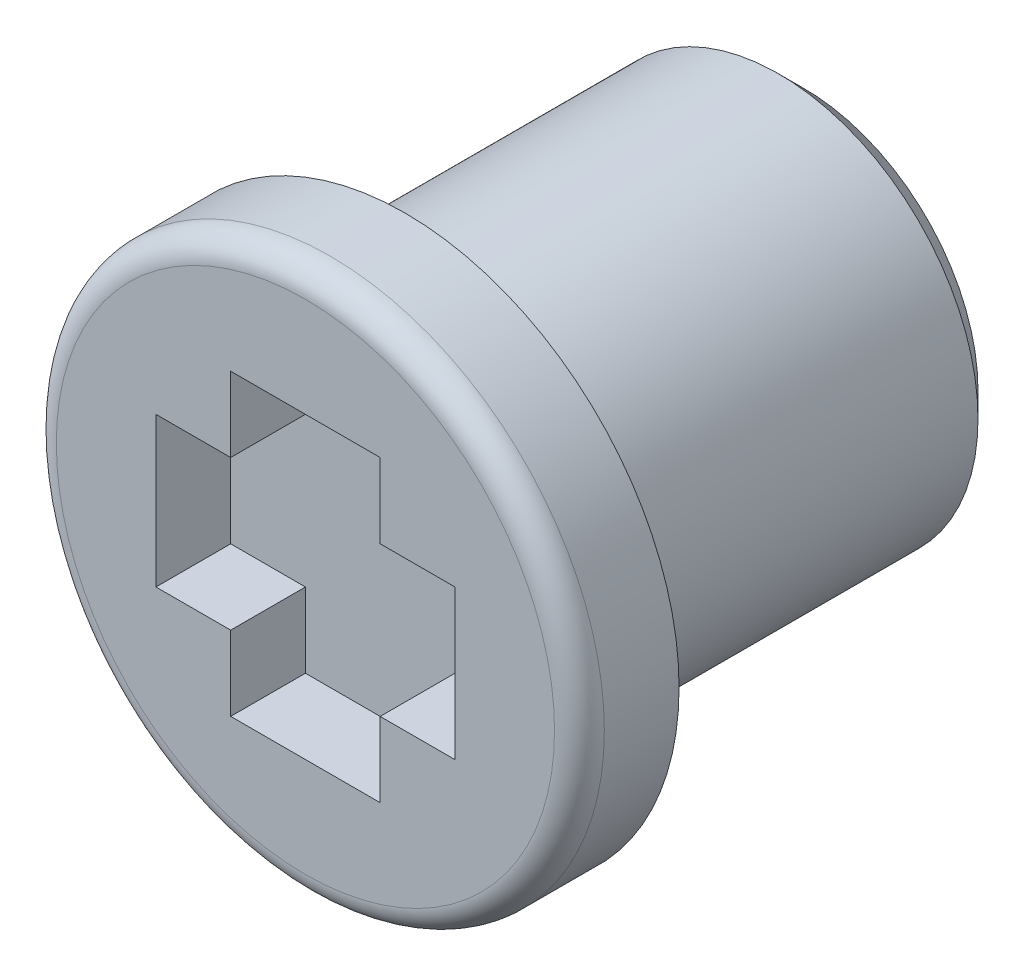
from build123d import *

# Parameters (mm, degrees)
SKETCH1_R           = 4
BOSS_EXTRUDE1_DEPTH = 8
SKETCH2_R           = 5.5
BOSS_EXTRUDE2_DEPTH = 2
CHAMFER1_SIZE       = 0.5
CUT_EXTRUDE1_DEPTH  = 1.5
FILLET1_R           = 0.5


with BuildPart() as part:
    # Sketch1 → Boss-Extrude1 (new body)
    with BuildSketch(Plane.XY):
        with Locations((0, 0.169439546)):
            Circle(SKETCH1_R)
    extrude(amount=BOSS_EXTRUDE1_DEPTH)

    # Sketch2 → Boss-Extrude2 (add)
    with BuildSketch(Plane.XY.offset(8)):
        Circle(SKETCH2_R)
    extrude(amount=BOSS_EXTRUDE2_DEPTH)

    # Chamfer1
    chamfer1_edges = [part.edges().sort_by_distance(p)[0] for p in [
        (-4, 0.169439546, 0),
    ]]
    chamfer(chamfer1_edges, length=CHAMFER1_SIZE)

    # Sketch4 → Cut-Extrude1 (cut)
    with BuildSketch(Plane.XY.offset(10)):
        Polygon((1.5, 1.5), (3, 1.5), (3, -1.50088727), (1.5, -1.50088727), (1.5, -3), (-1.5, -3), (-1.5, -1.50088727), (-3, -1.50088727), (-3, 0), (-3, 1.5), (-1.5, 1.5), (-1.5, 3), (0, 3), (1.5, 3), align=None)
    extrude(amount=-CUT_EXTRUDE1_DEPTH, mode=Mode.SUBTRACT)

    # Fillet1
    fillet1_edges = [part.edges().sort_by_distance(p)[0] for p in [
        (-5.5, 0, 10),
    ]]
    fillet(fillet1_edges, radius=FILLET1_R)


solid = part.part
